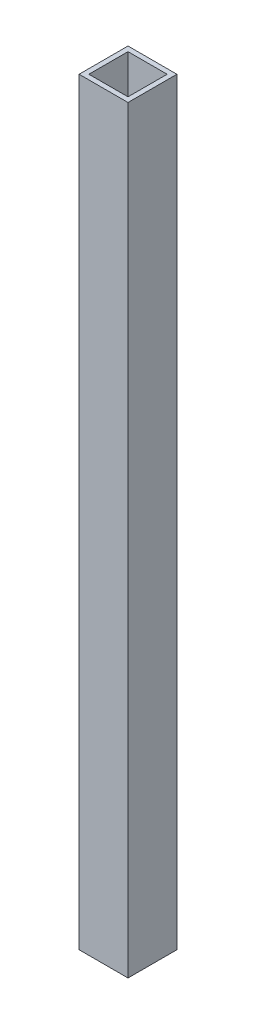
from build123d import *

# Parameters (mm, degrees)
SKETCH_1_W      = 10
SKETCH_1_H      = 10
SKETCH_1_W_2    = 8
SKETCH_1_H_2    = 8
EXTRUDE_1_DEPTH = 155


with BuildPart() as part:
    # 草图1 → 凸台-拉伸1 (new body)
    with BuildSketch(Plane.XZ.offset(155)):
        with Locations((40, 0)):
            Rectangle(SKETCH_1_W, SKETCH_1_H)
        with Locations((40, 0)):
            Rectangle(SKETCH_1_W_2, SKETCH_1_H_2, mode=Mode.SUBTRACT)
    extrude(amount=-EXTRUDE_1_DEPTH)


solid = part.part
